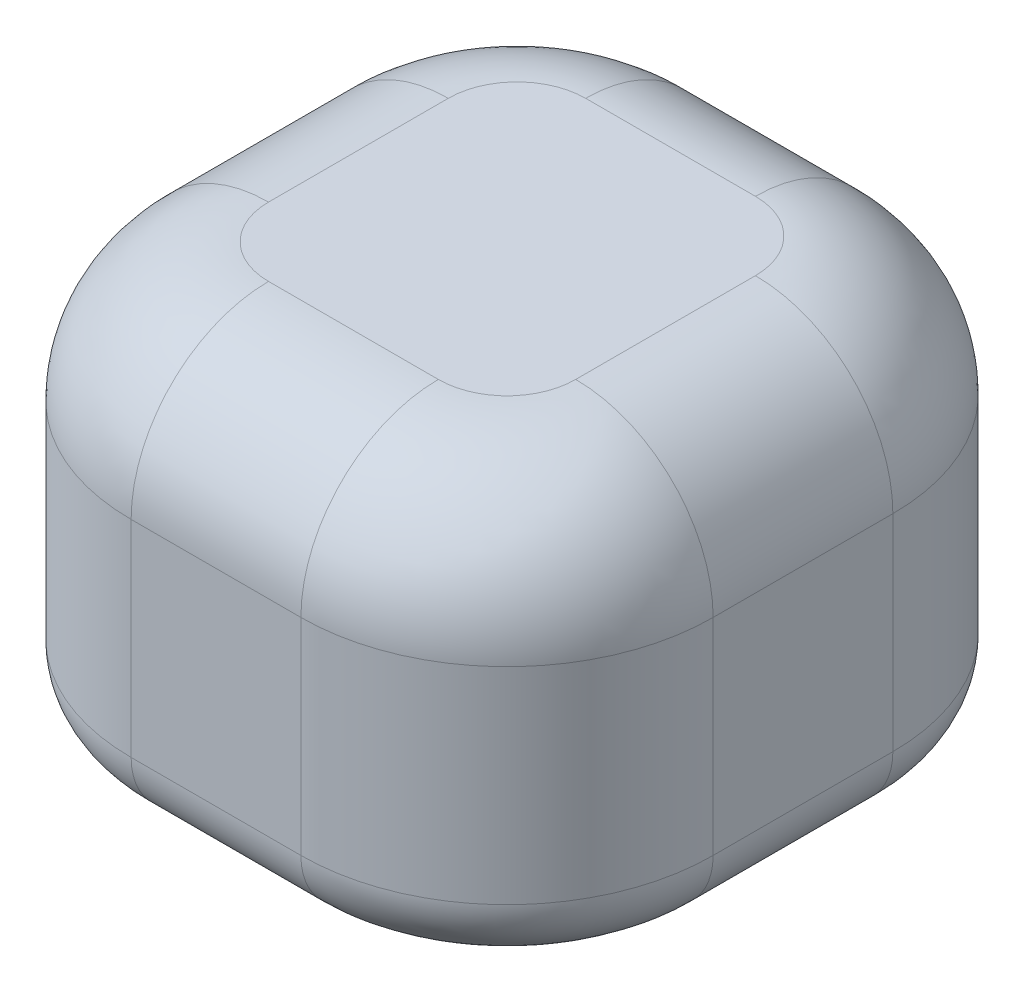
from build123d import *

# Parameters (mm, degrees)
SKETCH1_W                = 84.708364016
SKETCH1_H                = 86.159780402
BOSS_EXTRUDE1_DEPTH      = 30
BOSS_EXTRUDE1_DEPTH_BACK = 30
FILLET1_R                = 30
FILLET2_R                = 20
FILLET3_R                = 10


with BuildPart() as part:
    # Sketch1 → Boss-Extrude1 (new body, two sides)
    with BuildSketch(Plane(origin=(0, 0, 0), x_dir=(1, 0, 0), z_dir=(0, 1, 0))) as boss_extrude1_sk:
        Rectangle(SKETCH1_W, SKETCH1_H)
    extrude(amount=BOSS_EXTRUDE1_DEPTH)
    extrude(boss_extrude1_sk.sketch, amount=-BOSS_EXTRUDE1_DEPTH_BACK)

    # Fillet1
    fillet1_edges = [part.edges().sort_by_distance(p)[0] for p in [
        (42.354182008, 0, 43.079890201),
        (-42.354182008, 0, 43.079890201),
        (-42.354182008, 0, -43.079890201),
        (42.354182008, 0, -43.079890201),
    ]]
    fillet(fillet1_edges, radius=FILLET1_R)

    # Fillet2
    fillet2_edges = [part.edges().sort_by_distance(p)[0] for p in [
        (0, 30, 43.079890201),
        (42.354182008, 30, 0),
        (0, 30, -43.079890201),
        (-42.354182008, 30, 0),
        (-33.567385444, 30, -34.293093637),
        (-33.567385444, 30, 34.293093637),
        (33.567385444, 30, -34.293093637),
        (33.567385444, 30, 34.293093637),
    ]]
    fillet(fillet2_edges, radius=FILLET2_R)

    # Fillet3
    fillet3_edges = [part.edges().sort_by_distance(p)[0] for p in [
        (0, -30, 43.079890201),
        (42.354182008, -30, 0),
        (-42.354182008, -30, 0),
        (0, -30, -43.079890201),
        (-33.567385444, -30, -34.293093637),
        (-33.567385444, -30, 34.293093637),
        (33.567385444, -30, -34.293093637),
        (33.567385444, -30, 34.293093637),
    ]]
    fillet(fillet3_edges, radius=FILLET3_R)


solid = part.part
